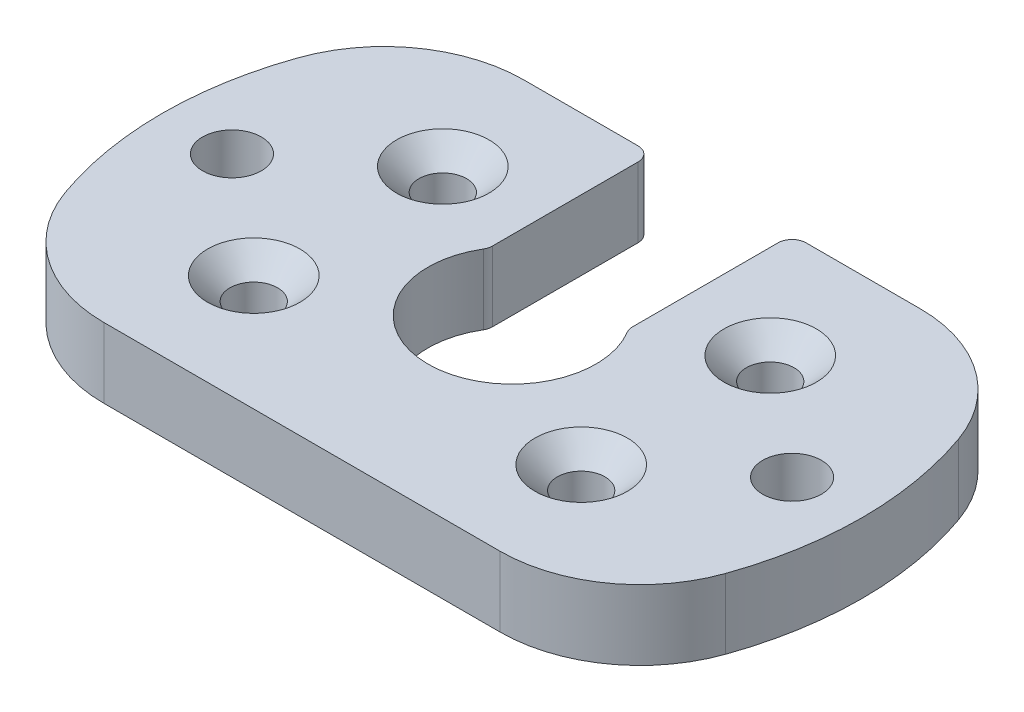
from build123d import *

# Parameters (mm, degrees)
SKETCH_1_R                   = 25
EXTRUDE_1_DEPTH              = 5
SKETCH_2_R                   = 1
CUT_EXTRUDE_1_DEPTH          = 4
HOLE_WIZARD_M3_1_D           = 3.4
HOLE_WIZARD_M3_1_DEPTH       = 7.5
HOLE_WIZARD_M3_1_CSINK_D     = 6.6
HOLE_WIZARD_M3_1_CSINK_ANGLE = 90
HOLE_WIZARD_M3_1_TIP         = 1.021463052
SKETCH_4_R                   = 2
CUT_EXTRUDE_2_DEPTH          = 4
HOLE_WIZARD_M5_1_D           = 4.2
HOLE_WIZARD_M5_1_DEPTH       = 12.4
HOLE_WIZARD_M5_1_TIP         = 1.2618073
SKETCH_7_W                   = 78.33195998
SKETCH_7_H                   = 10
CUT_EXTRUDE_3_DEPTH          = 36.707142143
FILLET_1_R                   = 10
SKETCH_9_R                   = 6
CUT_EXTRUDE_5_DEPTH          = 10
SKETCH_10_W                  = 10
SKETCH_10_H                  = 11.68337521
CUT_EXTRUDE_6_DEPTH          = 10
FILLET_2_R                   = 1


with BuildPart() as part:
    # 草图1 → 凸台-拉伸1 (new body)
    with BuildSketch(Plane(origin=(0, 0, 0), x_dir=(1, 0, 0), z_dir=(0, 1, 0))):
        Circle(SKETCH_1_R)
    extrude(amount=EXTRUDE_1_DEPTH)

    # 草图2 → 切除-拉伸1 (cut)
    with BuildSketch(Plane(origin=(0, 5, 0), x_dir=(1, 0, 0), z_dir=(0, 1, 0))):
        with Locations((11.691342951, 6.75)):
            Circle(SKETCH_2_R)
        with Locations((11.691342951, -6.75)):
            Circle(SKETCH_2_R)
        with Locations((-11.691342951, -6.75)):
            Circle(SKETCH_2_R)
        with Locations((-11.691342951, 6.75)):
            Circle(SKETCH_2_R)
    extrude(amount=-CUT_EXTRUDE_1_DEPTH, mode=Mode.SUBTRACT)

    # M3 十字槽沉头木螺钉的锥形沉头孔1
    with Locations(Plane(origin=(11.691342951, 5, -6.75), x_dir=(0, 0, 1), z_dir=(0, 1, 0))):
        with Locations((0, 0), (13.5, 0), (13.5, -23.382685902), (0, -23.382685902)):
            CounterSinkHole(HOLE_WIZARD_M3_1_D / 2, HOLE_WIZARD_M3_1_CSINK_D / 2, depth=HOLE_WIZARD_M3_1_DEPTH, counter_sink_angle=HOLE_WIZARD_M3_1_CSINK_ANGLE)
            with Locations((0, 0, -(HOLE_WIZARD_M3_1_DEPTH + HOLE_WIZARD_M3_1_TIP / 2))):  # 118° drill point
                Cone(0, HOLE_WIZARD_M3_1_D / 2, HOLE_WIZARD_M3_1_TIP, mode=Mode.SUBTRACT)

    # 草图4 → 切除-拉伸2 (cut)
    with BuildSketch(Plane(origin=(0, 5, 0), x_dir=(1, 0, 0), z_dir=(0, 1, 0))):
        with Locations((-20, 0)):
            Circle(SKETCH_4_R)
        with Locations((20, 0)):
            Circle(SKETCH_4_R)
    extrude(amount=-CUT_EXTRUDE_2_DEPTH, mode=Mode.SUBTRACT)

    # M5 螺纹孔1
    with Locations(Plane(origin=(-20, 5, 0), x_dir=(0, 0, 1), z_dir=(0, 1, 0))):
        with Locations((0, 0), (0, 40)):
            Hole(HOLE_WIZARD_M5_1_D / 2, depth=HOLE_WIZARD_M5_1_DEPTH)
            with Locations((0, 0, -(HOLE_WIZARD_M5_1_DEPTH + HOLE_WIZARD_M5_1_TIP / 2))):  # 118° drill point
                Cone(0, HOLE_WIZARD_M5_1_D / 2, HOLE_WIZARD_M5_1_TIP, mode=Mode.SUBTRACT)

    # 草图7 → 切除-拉伸3 (cut, through all)
    with BuildSketch(Plane(origin=(0, 5, 0), x_dir=(1, 0, 0), z_dir=(0, 1, 0))):
        with Locations((0, 20)):
            Rectangle(SKETCH_7_W, SKETCH_7_H)
        with Locations((0, -20)):
            Rectangle(SKETCH_7_W, SKETCH_7_H)
    extrude(amount=-CUT_EXTRUDE_3_DEPTH, mode=Mode.SUBTRACT)

    # 圆角1
    fillet_1_edges = [part.edges().sort_by_distance(p)[0] for p in [
        (20, 2.5, -15),
        (20, 2.5, 15),
        (-20, 2.5, -15),
        (-20, 2.5, 15),
    ]]
    fillet(fillet_1_edges, radius=FILLET_1_R)

    # 草图9 → 切除-拉伸5 (cut)
    with BuildSketch(Plane(origin=(0, 5, 0), x_dir=(1, 0, 0), z_dir=(0, 1, 0))):
        Circle(SKETCH_9_R)
    extrude(amount=-CUT_EXTRUDE_5_DEPTH, mode=Mode.SUBTRACT)

    # 草图10 → 切除-拉伸6 (cut)
    with BuildSketch(Plane(origin=(0, 5, 0), x_dir=(1, 0, 0), z_dir=(0, 1, 0))):
        with Locations((0, 9.158312395)):
            Rectangle(SKETCH_10_W, SKETCH_10_H)
    extrude(amount=-CUT_EXTRUDE_6_DEPTH, mode=Mode.SUBTRACT)

    # 圆角2
    fillet_2_edges = [part.edges().sort_by_distance(p)[0] for p in [
        (5, 2.5, -3.31662479),
        (-5, 2.5, -3.31662479),
        (5, 2.5, -15),
        (-5, 2.5, -15),
    ]]
    fillet(fillet_2_edges, radius=FILLET_2_R)


solid = part.part
